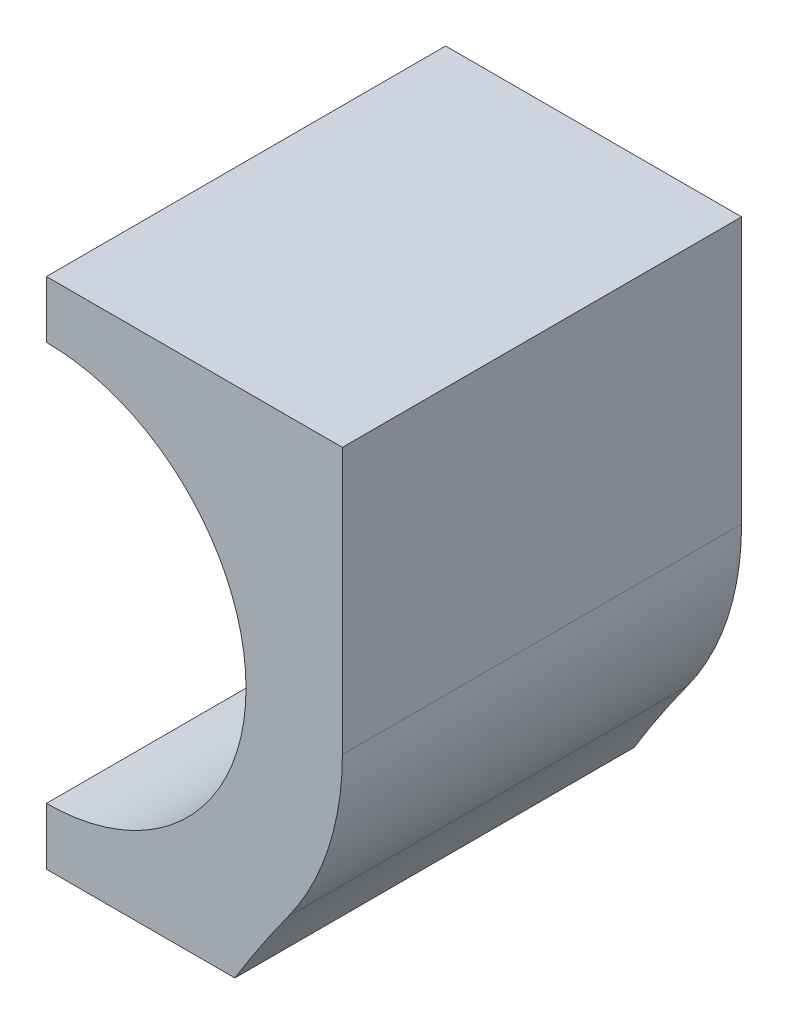
from build123d import *

# Parameters (mm, degrees)
EXTRUDE_1_DEPTH = 14


with BuildPart() as part:
    # 草图1 → 凸台-拉伸1 (new body)
    with BuildSketch(Plane.XY):
        with BuildLine():
            Line((-4.335050742, 439.946209227), (-4.335050742, 449.276757584))
            Line((-4.335050742, 449.276757584), (-14.712951443, 449.276757584))
            Line((-14.712951443, 449.276757584), (-14.712951443, 447.276757584))
            ThreePointArc((-14.712951443, 447.276757584), (-7.712951443, 440.276757584), (-14.712951443, 433.276757584))
            Line((-14.712951443, 433.276757584), (-14.712951443, 431.276757584))
            Line((-14.712951443, 431.276757584), (-8.105031432, 431.276757584))
            ThreePointArc((-8.105031432, 431.276757584), (-7.200115769, 432.694505685), (-6.239812646, 434.075338748))
            ThreePointArc((-6.239812646, 434.075338748), (-4.823153429, 436.860142228), (-4.335050742, 439.946209227))
        make_face()
    extrude(amount=EXTRUDE_1_DEPTH)


solid = part.part
